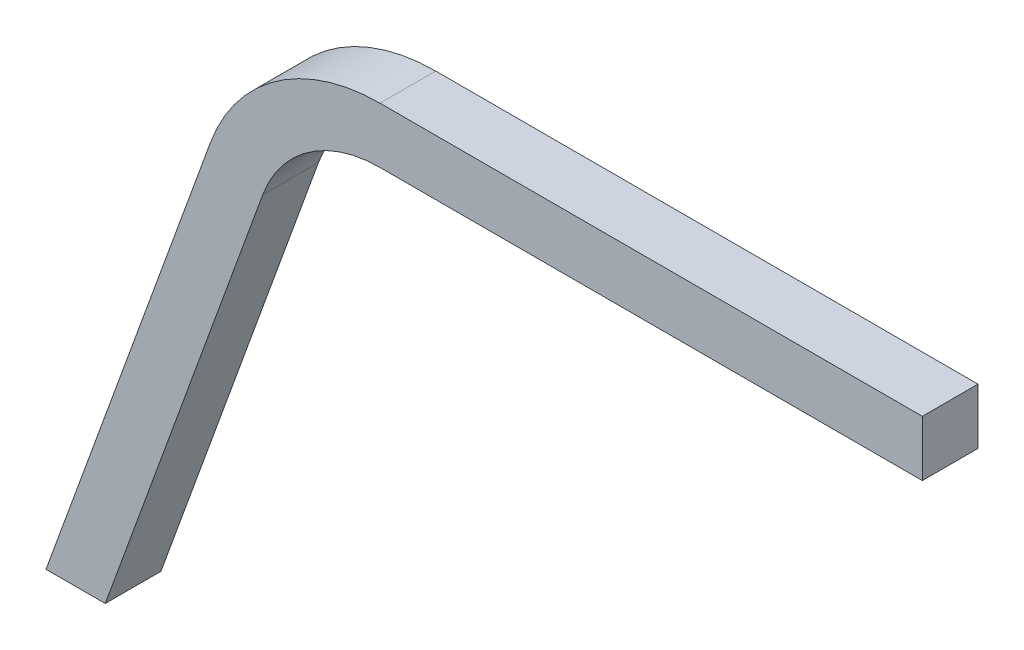
from build123d import *

# Parameters (mm, degrees)
EXTRUDE1_DEPTH = 6.35


with BuildPart() as part:
    # Sketch1 → Extrude1 (new body)
    with BuildSketch(Plane.XY):
        with BuildLine():
            Line((99.949, 65.0875), (99.949, 58.7375))
            Line((99.949, 58.7375), (38.1, 58.7375))
            ThreePointArc((38.1, 58.7375), (29.938157837, 56.164081051), (24.728420615, 49.374619317))
            Line((24.728420615, 49.374619317), (6.757528855, 0))
            Line((6.757528855, 0), (0, 0))
            Line((0, 0), (18.761372473, 51.546447227))
            ThreePointArc((18.761372473, 51.546447227), (26.295947467, 61.365696532), (38.1, 65.0875))
            Line((38.1, 65.0875), (99.949, 65.0875))
        make_face()
    extrude(amount=EXTRUDE1_DEPTH)


solid = part.part
